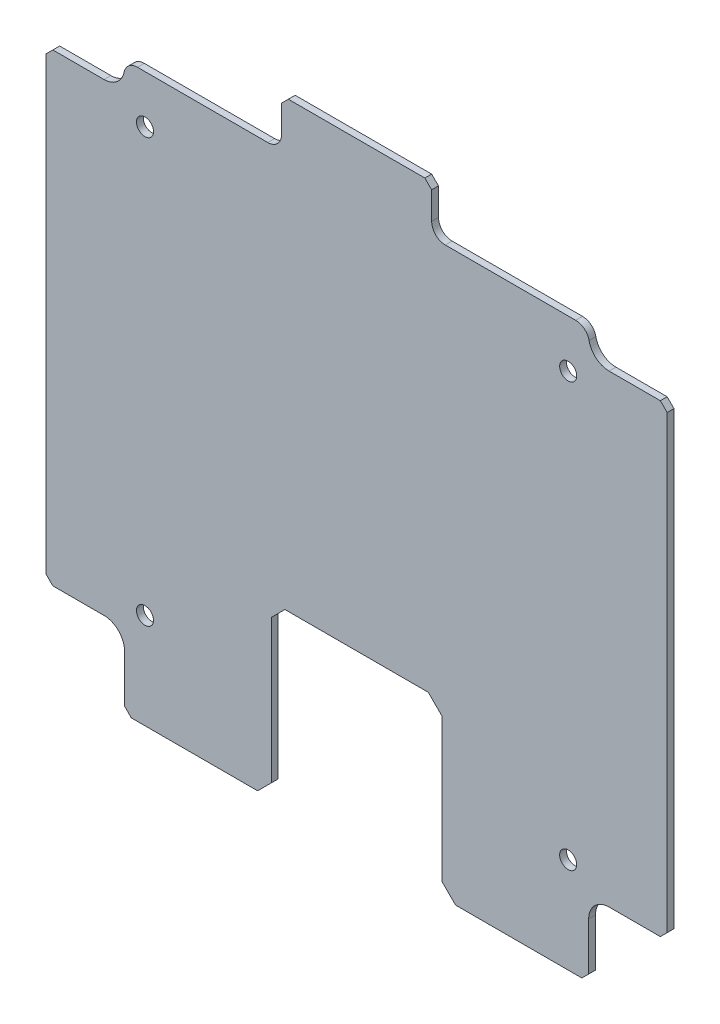
from build123d import *

# Parameters (mm, degrees)
SKETCH_1_W          = 68
SKETCH_1_H          = 68
SKETCH_1_R          = 1.25
SKETCH_1_H_2        = 11
SKETCH_1_W_2        = 11.5
EXTRUDE_2_DEPTH     = 1
FILLET_1_R          = 3
SKETCH_3_W          = 25
SKETCH_3_H          = 25
CUT_EXTRUDE_1_DEPTH = 2
CHAMFER_1_SIZE      = 2
SKETCH_5_W          = 23
SKETCH_5_H          = 7
CUT_EXTRUDE_2_DEPTH = 2
FILLET_2_R          = 2
CHAMFER_2_SIZE      = 1


with BuildPart() as part:
    # ｽｹｯﾁ1 → ﾎﾞｽ - 押し出し2 (new body)
    with BuildSketch(Plane.XY):
        Rectangle(SKETCH_1_W, SKETCH_1_H)
        with Locations((-31, -31)):
            Circle(SKETCH_1_R, mode=Mode.SUBTRACT)
        with Locations((31, -31)):
            Circle(SKETCH_1_R, mode=Mode.SUBTRACT)
        with Locations((-31, 31)):
            Circle(SKETCH_1_R, mode=Mode.SUBTRACT)
        with Locations((31, 31)):
            Circle(SKETCH_1_R, mode=Mode.SUBTRACT)
        with Locations((0, 39.5)):
            Rectangle(SKETCH_1_W, SKETCH_1_H_2)
        with Locations((-39.75, 0)):
            Rectangle(SKETCH_1_W_2, SKETCH_1_H)
        with Locations((39.75, 0)):
            Rectangle(SKETCH_1_W_2, SKETCH_1_H)
        with Locations((0, -39.5)):
            Rectangle(SKETCH_1_W, SKETCH_1_H_2)
    extrude(amount=EXTRUDE_2_DEPTH)

    # ﾌｨﾚｯﾄ1
    fillet_1_edges = [part.edges().sort_by_distance(p)[0] for p in [
        (-34, -34, 0.5),
        (-34, 34, 0.5),
        (34, 34, 0.5),
        (34, -34, 0.5),
    ]]
    fillet(fillet_1_edges, radius=FILLET_1_R)

    # ｽｹｯﾁ3 → ｶｯﾄ - 押し出し1 (cut, through all)
    with BuildSketch(Plane.XY.offset(1)):
        with Locations((0, -32.5)):
            Rectangle(SKETCH_3_W, SKETCH_3_H)
    extrude(amount=-CUT_EXTRUDE_1_DEPTH, mode=Mode.SUBTRACT)

    # 面取り1
    chamfer_1_edges = [part.edges().sort_by_distance(p)[0] for p in [
        (-12.5, -45, 0.5),
        (-12.5, -20, 0.5),
        (12.5, -20, 0.5),
        (12.5, -45, 0.5),
    ]]
    chamfer(chamfer_1_edges, length=CHAMFER_1_SIZE)

    # ｽｹｯﾁ5 → ｶｯﾄ - 押し出し2 (cut, through all)
    with BuildSketch(Plane.XY.offset(1)):
        with Locations((-22.5, 41.5)):
            Rectangle(SKETCH_5_W, SKETCH_5_H)
        with Locations((22.5, 41.5)):
            Rectangle(SKETCH_5_W, SKETCH_5_H)
    extrude(amount=-CUT_EXTRUDE_2_DEPTH, mode=Mode.SUBTRACT)

    # ﾌｨﾚｯﾄ2
    fillet_2_edges = [part.edges().sort_by_distance(p)[0] for p in [
        (11, 38, 0.5),
        (34, 38, 0.5),
        (-11, 38, 0.5),
        (-34, 38, 0.5),
    ]]
    fillet(fillet_2_edges, radius=FILLET_2_R)

    # 面取り2
    chamfer_2_edges = [part.edges().sort_by_distance(p)[0] for p in [
        (-11, 45, 0.5),
        (11, 45, 0.5),
        (34, -45, 0.5),
        (-34, -45, 0.5),
        (-45.5, -34, 0.5),
        (-45.5, 34, 0.5),
        (45.5, 34, 0.5),
        (45.5, -34, 0.5),
    ]]
    chamfer(chamfer_2_edges, length=CHAMFER_2_SIZE)


solid = part.part
